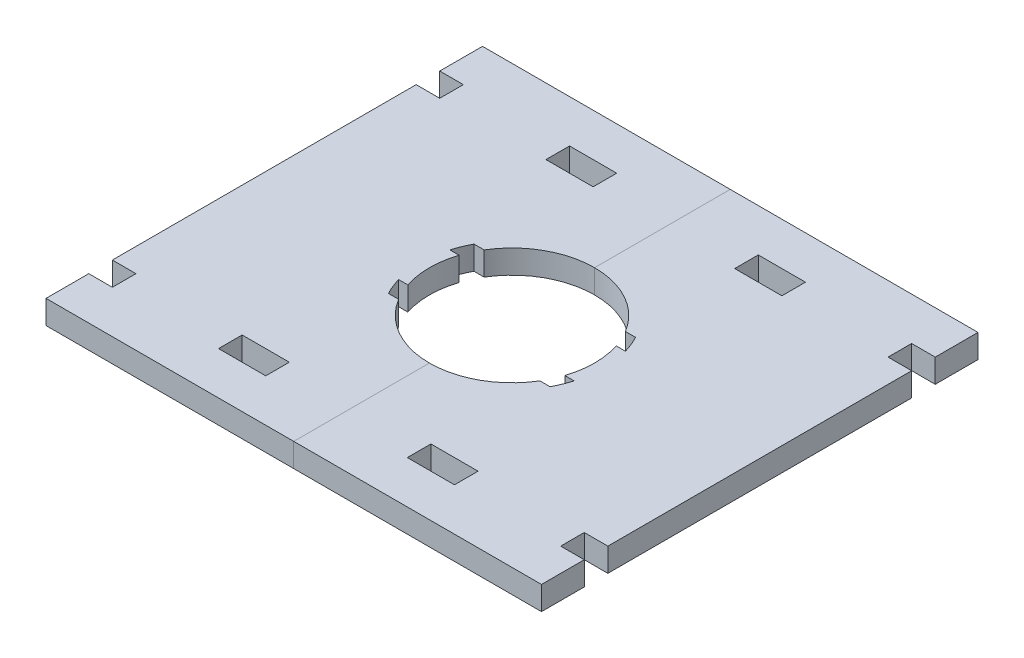
from build123d import *

# Parameters (mm, degrees)
SKETCH2_W               = 84
SKETCH2_H               = 74
BOSS_EXTRUDE1_DEPTH     = 4
SKETCH4_W               = 8
SKETCH4_H               = 4
SKETCH4_W_2             = 4
CUT_EXTRUDE2_DEPTH      = 1
CUT_EXTRUDE2_DEPTH_BACK = 5


with BuildPart() as part:
    # Sketch2 → Boss-Extrude1 (new body)
    with BuildSketch(Plane(origin=(0, 0, 0), x_dir=(1, 0, 0), z_dir=(0, 1, 0))):
        Rectangle(SKETCH2_W, SKETCH2_H)
        with BuildLine():
            ThreePointArc((13.307047005, 4.35), (14, 0), (13.307047005, -4.35))
            Line((13.307047005, -4.35), (14.877079687, -4.35))
            ThreePointArc((14.877079687, -4.35), (14.361878956, -5.829788405), (13.699908759, -7.25))
            Line((13.699908759, -7.25), (11.976539567, -7.25))
            ThreePointArc((11.976539567, -7.25), (0, -14), (-11.976539567, -7.25))
            Line((-11.976539567, -7.25), (-13.699908759, -7.25))
            ThreePointArc((-13.699908759, -7.25), (-14.361878956, -5.829788405), (-14.877079687, -4.35))
            Line((-14.877079687, -4.35), (-13.307047005, -4.35))
            ThreePointArc((-13.307047005, -4.35), (-14, 0), (-13.307047005, 4.35))
            Line((-13.307047005, 4.35), (-14.877079687, 4.35))
            ThreePointArc((-14.877079687, 4.35), (-14.361878956, 5.829788405), (-13.699908759, 7.25))
            Line((-13.699908759, 7.25), (-11.976539567, 7.25))
            ThreePointArc((-11.976539567, 7.25), (0, 14), (11.976539567, 7.25))
            Line((11.976539567, 7.25), (13.699908759, 7.25))
            ThreePointArc((13.699908759, 7.25), (14.361878956, 5.829788405), (14.877079687, 4.35))
            Line((14.877079687, 4.35), (13.307047005, 4.35))
        make_face(mode=Mode.SUBTRACT)
    extrude(amount=BOSS_EXTRUDE1_DEPTH)


with BuildPart() as body_2:
    # Split1: the piece on the far side of the plane
    add(part.part)
    split(bisect_by=Plane(origin=(0, 0, 0), x_dir=(0, 0, 1), z_dir=(1, 0, 0)), keep=Keep.BOTTOM)


with BuildPart() as part_1:
    add(part.part)

    # Split1
    split(bisect_by=Plane(origin=(0, 0, 0), x_dir=(0, 0, 1), z_dir=(1, 0, 0)), keep=Keep.TOP)


with BuildPart() as cut_extrude2_tool:
    # Sketch4 → Cut-Extrude2 (new body, two sides)
    with BuildSketch(Plane(origin=(0, 4, 0), x_dir=(1, 0, 0), z_dir=(0, 1, 0))) as cut_extrude2_sk:
        with Locations((-16, -27.75)):
            Rectangle(SKETCH4_W, SKETCH4_H)
        with Locations((-40, -27.75)):
            Rectangle(SKETCH4_W_2, SKETCH4_H)
        with Locations((40, -27.75)):
            Rectangle(SKETCH4_W_2, SKETCH4_H)
        with Locations((16, -27.75)):
            Rectangle(SKETCH4_W, SKETCH4_H)
        with Locations((16, 27.75)):
            Rectangle(SKETCH4_W, SKETCH4_H)
        with Locations((40, 27.75)):
            Rectangle(SKETCH4_W_2, SKETCH4_H)
        with Locations((-40, 27.75)):
            Rectangle(SKETCH4_W_2, SKETCH4_H)
        with Locations((-16, 27.75)):
            Rectangle(SKETCH4_W, SKETCH4_H)
    extrude(amount=CUT_EXTRUDE2_DEPTH)
    extrude(cut_extrude2_sk.sketch, amount=-CUT_EXTRUDE2_DEPTH_BACK)


with BuildPart() as part_2:
    add(part_1.part)

    # Cut-Extrude2: cut by cut_extrude2_tool
    add(cut_extrude2_tool.part, mode=Mode.SUBTRACT)


with BuildPart() as body_2_1:
    add(body_2.part)

    # Cut-Extrude2: cut by cut_extrude2_tool
    add(cut_extrude2_tool.part, mode=Mode.SUBTRACT)


solid = Compound([part_2.part, body_2_1.part])
